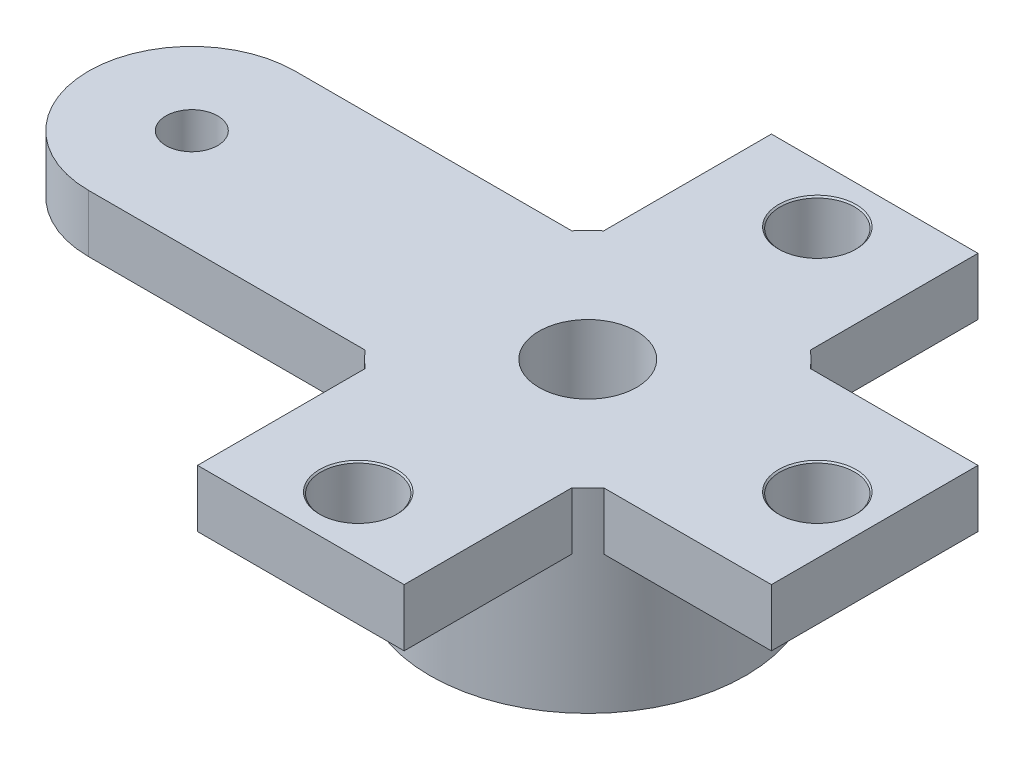
from build123d import *

# Parameters (mm, degrees)
SKETCH_1_R                       = 2.75
SKETCH_1_R_2                     = 0.85
EXTRUDE_1_DEPTH                  = 3.4
SKETCH_2_R                       = 0.45
EXTRUDE_2_DEPTH                  = 1
SKETCH_3_R                       = 0.45
CUT_EXTRUDE_1_DEPTH              = 4.4
HOLE_WIZARD_1_3_1_3_1_AT_2_COUNT = 2
HOLE_WIZARD_1_3_1_3_1_AT_2_PITCH = 5.656854249
HOLE_WIZARD_1_3_1_3_1_AT_3_COUNT = 2
HOLE_WIZARD_1_3_1_3_1_AT_3_PITCH = 8


with BuildPart() as part:
    # Эскиз1 → Бобышка-Вытянуть1 (new body)
    with BuildSketch(Plane(origin=(0, 0, 0), x_dir=(1, 0, 0), z_dir=(0, 1, 0))):
        Circle(SKETCH_1_R)
        Circle(SKETCH_1_R_2, mode=Mode.SUBTRACT)
    extrude(amount=EXTRUDE_1_DEPTH)

    # Эскиз2 → Бобышка-Вытянуть2 (add)
    with BuildSketch(Plane(origin=(0, 3.4, 0), x_dir=(1, 0, 0), z_dir=(0, 1, 0))):
        with BuildLine():
            Line((6.9, 1.8), (2.079062289, 1.8))
            ThreePointArc((2.079062289, 1.8), (2.75, 0), (2.079062289, -1.8))
            Line((2.079062289, -1.8), (6.9, -1.8))
            ThreePointArc((6.9, -1.8), (8.7, 0), (6.9, 1.8))
        make_face()
        with Locations((6.9, 0)):
            Circle(SKETCH_2_R, mode=Mode.SUBTRACT)
        with BuildLine():
            ThreePointArc((-1.8, 2.079062289), (0, 2.75), (1.8, 2.079062289))
            Line((1.8, 2.079062289), (1.8, 6.9))
            ThreePointArc((1.8, 6.9), (0, 8.7), (-1.8, 6.9))
            Line((-1.8, 6.9), (-1.8, 2.079062289))
        make_face()
        with Locations((0, 6.9)):
            Circle(SKETCH_2_R, mode=Mode.SUBTRACT)
        with BuildLine():
            Line((1.8, -6.9), (1.8, -2.079062289))
            ThreePointArc((1.8, -2.079062289), (0, -2.75), (-1.8, -2.079062289))
            Line((-1.8, -2.079062289), (-1.8, -6.9))
            ThreePointArc((-1.8, -6.9), (0, -8.7), (1.8, -6.9))
        make_face()
        with Locations((0, -6.9)):
            Circle(SKETCH_2_R, mode=Mode.SUBTRACT)
        with BuildLine():
            ThreePointArc((-2.079062289, -1.8), (-2.75, 0), (-2.079062289, 1.8))
            Line((-2.079062289, 1.8), (-6.9, 1.8))
            ThreePointArc((-6.9, 1.8), (-8.7, 0), (-6.9, -1.8))
            Line((-6.9, -1.8), (-2.079062289, -1.8))
        make_face()
        with Locations((-6.9, 0)):
            Circle(SKETCH_2_R, mode=Mode.SUBTRACT)
    extrude(amount=-EXTRUDE_2_DEPTH)

    # Эскиз3 → Вырез-Вытянуть1 (cut, through all)
    with BuildSketch(Plane(origin=(0, 3.4, 0), x_dir=(1, 0, 0), z_dir=(0, 1, 0))):
        with BuildLine():
            Line((6.9, 1.8), (5, 1.8))
            Line((5, 1.8), (5, -1.8))
            Line((5, -1.8), (6.9, -1.8))
            ThreePointArc((6.9, -1.8), (8.7, 0), (6.9, 1.8))
        make_face()
        with Locations((6.9, 0)):
            Circle(SKETCH_3_R, mode=Mode.SUBTRACT)
        with BuildLine():
            Line((1.8, -5), (-1.8, -5))
            Line((-1.8, -5), (-1.8, -6.9))
            ThreePointArc((-1.8, -6.9), (0, -8.7), (1.8, -6.9))
            Line((1.8, -6.9), (1.8, -5))
        make_face()
        with Locations((0, -6.9)):
            Circle(SKETCH_3_R, mode=Mode.SUBTRACT)
        with BuildLine():
            Line((-1.8, 6.9), (-1.8, 5))
            Line((-1.8, 5), (1.8, 5))
            Line((1.8, 5), (1.8, 6.9))
            ThreePointArc((1.8, 6.9), (0, 8.7), (-1.8, 6.9))
        make_face()
        with Locations((0, 6.9)):
            Circle(SKETCH_3_R, mode=Mode.SUBTRACT)
    extrude(amount=-CUT_EXTRUDE_1_DEPTH, mode=Mode.SUBTRACT)

    # Эскиз4 → Диаметр отверстия Ø1.3 (1.3)1 (revolve, cut)
    with BuildSketch(Plane(origin=(0, 2.4, -4), x_dir=(0, 0, -1), z_dir=(1, 0, 0))):
        Polygon((0, 0), (0, 1), (0.675, 1), (0.65, 0.975), (0.65, 0.025), (0.675, 0), align=None)
    hole_wizard_1_3_1_3_1 = revolve(axis=Axis((0, -3.95, -4), (0, 1, 0)), mode=Mode.SUBTRACT)

    # Диаметр отверстия Ø1.3 (1.3)1 at 2: Диаметр отверстия Ø1.3 (1.3)1 ×2
    with Locations(*[Vector(0.707106781, 0, 0.707106781) * (i * HOLE_WIZARD_1_3_1_3_1_AT_2_PITCH) for i in range(1, HOLE_WIZARD_1_3_1_3_1_AT_2_COUNT)]):
        add(hole_wizard_1_3_1_3_1, mode=Mode.SUBTRACT)

    # Диаметр отверстия Ø1.3 (1.3)1 at 3: Диаметр отверстия Ø1.3 (1.3)1 ×2
    with Locations(*[(0, 0, i * HOLE_WIZARD_1_3_1_3_1_AT_3_PITCH) for i in range(1, HOLE_WIZARD_1_3_1_3_1_AT_3_COUNT)]):
        add(hole_wizard_1_3_1_3_1, mode=Mode.SUBTRACT)


solid = part.part
